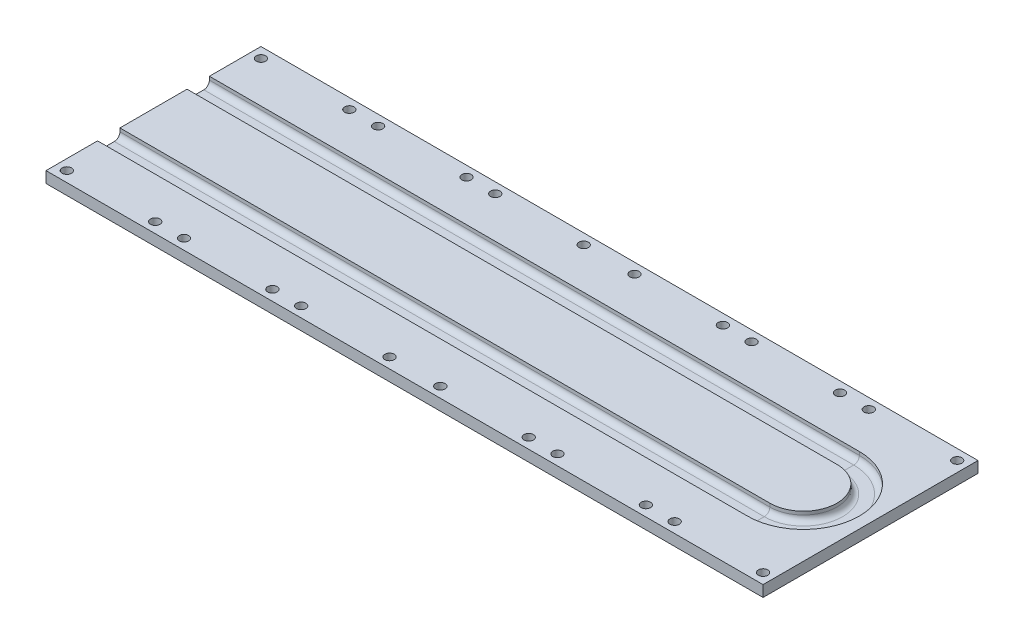
from build123d import *

# Parameters (mm, degrees)
SKETCH1_W                         = 407
SKETCH1_H                         = 122
BASE_PLATE_DEPTH                  = 6.35
SKETCH2_R                         = 2.675
IGBT_HOLES_DEPTH                  = 7.35
IGBT_HOLES_PATTERN_COUNT          = 3
IGBT_HOLES_PATTERN_PITCH          = 66.5
IGBT_HOLES_MIRROR_COPY_1_SKETCH_R = 2.675
IGBT_HOLES_MIRROR_COPY_1_DEPTH    = 7.35
IGBT_HOLES_MIRROR_COPY_2_SKETCH_R = 2.675
IGBT_HOLES_MIRROR_COPY_2_DEPTH    = 7.35


with BuildPart() as part:
    # Sketch1 → Base Plate (new body)
    with BuildSketch(Plane(origin=(0, 0, 0), x_dir=(1, 0, 0), z_dir=(0, 1, 0))):
        Rectangle(SKETCH1_W, SKETCH1_H)
    extrude(amount=BASE_PLATE_DEPTH)

    # Sketch2 → IGBT Holes (cut, through all)
    with BuildSketch(Plane(origin=(0, 6.35, 0), x_dir=(1, 0, 0), z_dir=(0, 1, 0))):
        with Locations((197.595, 55.095)):
            Circle(SKETCH2_R)
        with Locations((197.595, -55.095)):
            Circle(SKETCH2_R)
        with Locations((147.41, -55.095)):
            Circle(SKETCH2_R)
        with Locations((147.41, 55.095)):
            Circle(SKETCH2_R)
    igbt_holes = extrude(amount=-IGBT_HOLES_DEPTH, mode=Mode.SUBTRACT)

    # IGBT Holes Pattern: IGBT Holes ×3
    with Locations(*[(-i * IGBT_HOLES_PATTERN_PITCH, 0, 0) for i in range(1, IGBT_HOLES_PATTERN_COUNT)]):
        add(igbt_holes, mode=Mode.SUBTRACT)

    # IGBT Holes Mirror: IGBT Holes across plane
    add(igbt_holes.mirror(Plane(origin=(0, 0, 0), x_dir=(0, 0, 1), z_dir=(1, 0, 0))), mode=Mode.SUBTRACT)

    # IGBT Holes Mirror copy 1 sketch → IGBT Holes Mirror copy 1 (cut, through all)
    with BuildSketch(Plane(origin=(66.5, 6.35, 0), x_dir=(-1, 0, 0), z_dir=(0, 1, 0))):
        with Locations((197.595, -55.095)):
            Circle(IGBT_HOLES_MIRROR_COPY_1_SKETCH_R)
        with Locations((197.595, 55.095)):
            Circle(IGBT_HOLES_MIRROR_COPY_1_SKETCH_R)
        with Locations((147.41, 55.095)):
            Circle(IGBT_HOLES_MIRROR_COPY_1_SKETCH_R)
        with Locations((147.41, -55.095)):
            Circle(IGBT_HOLES_MIRROR_COPY_1_SKETCH_R)
    extrude(amount=-IGBT_HOLES_MIRROR_COPY_1_DEPTH, mode=Mode.SUBTRACT)

    # IGBT Holes Mirror copy 2 sketch → IGBT Holes Mirror copy 2 (cut, through all)
    with BuildSketch(Plane(origin=(133, 6.35, 0), x_dir=(-1, 0, 0), z_dir=(0, 1, 0))):
        with Locations((197.595, -55.095)):
            Circle(IGBT_HOLES_MIRROR_COPY_2_SKETCH_R)
        with Locations((197.595, 55.095)):
            Circle(IGBT_HOLES_MIRROR_COPY_2_SKETCH_R)
        with Locations((147.41, 55.095)):
            Circle(IGBT_HOLES_MIRROR_COPY_2_SKETCH_R)
        with Locations((147.41, -55.095)):
            Circle(IGBT_HOLES_MIRROR_COPY_2_SKETCH_R)
    extrude(amount=-IGBT_HOLES_MIRROR_COPY_2_DEPTH, mode=Mode.SUBTRACT)

    # Pipe Profile: sweep along a path in Sketch3
    with BuildLine(Plane(origin=(0, 6.35, 0), x_dir=(1, 0, 0), z_dir=(0, 1, 0))) as pipe_profile_path:
        Line((-203.5, 25.4), (165.4, 25.4))
        ThreePointArc((165.4, 25.4), (190.8, 0), (165.4, -25.4))
        Line((165.4, -25.4), (-203.5, -25.4))
    # Sketch4 → Pipe Profile (sweep, cut)
    with BuildSketch(Plane.ZY.offset(203.5)):
        with BuildLine():
            Line((-28.575, 1.27), (-22.225, 1.27))
            ThreePointArc((-22.225, 1.27), (-19.97993597, 2.19993597), (-19.05, 4.445))
            Line((-19.05, 4.445), (-19.05, 6.35))
            Line((-19.05, 6.35), (-31.75, 6.35))
            Line((-31.75, 6.35), (-31.75, 4.445))
            ThreePointArc((-31.75, 4.445), (-30.82006403, 2.19993597), (-28.575, 1.27))
        make_face()
    sweep(path=pipe_profile_path.line, mode=Mode.SUBTRACT)


solid = part.part
